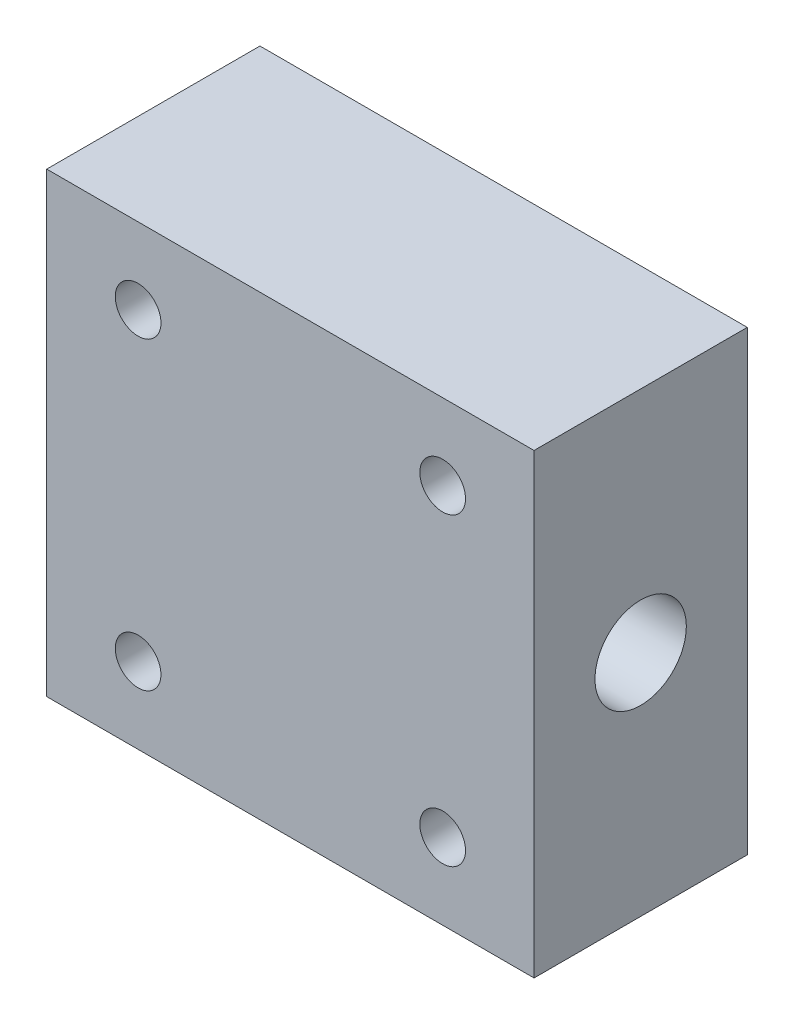
from build123d import *

# Parameters (mm, degrees)
SKETCH_1_W          = 32
SKETCH_1_H          = 30
EXTRUDE_1_DEPTH     = 14
SKETCH_2_R          = 3
CUT_EXTRUDE_1_DEPTH = 33
SKETCH_3_R          = 1.5
CUT_EXTRUDE_2_DEPTH = 3


with BuildPart() as part:
    # 草图1 → 凸台-拉伸1 (new body)
    with BuildSketch(Plane.XY):
        Rectangle(SKETCH_1_W, SKETCH_1_H)
    extrude(amount=EXTRUDE_1_DEPTH)

    # 草图2 → 切除-拉伸1 (cut)
    with BuildSketch(Plane(origin=(16, 0, 0), x_dir=(0, 0, -1), z_dir=(1, 0, 0))):
        with Locations((-7, 0)):
            Circle(SKETCH_2_R)
    extrude(amount=-CUT_EXTRUDE_1_DEPTH, mode=Mode.SUBTRACT)

    # 草图3 → 切除-拉伸2 (cut)
    with BuildSketch(Plane.XY.offset(14)):
        with Locations((-10, 10)):
            Circle(SKETCH_3_R)
        with Locations((10, 10)):
            Circle(SKETCH_3_R)
        with Locations((10, -10)):
            Circle(SKETCH_3_R)
        with Locations((-10, -10)):
            Circle(SKETCH_3_R)
    extrude(amount=-CUT_EXTRUDE_2_DEPTH, mode=Mode.SUBTRACT)


solid = part.part
